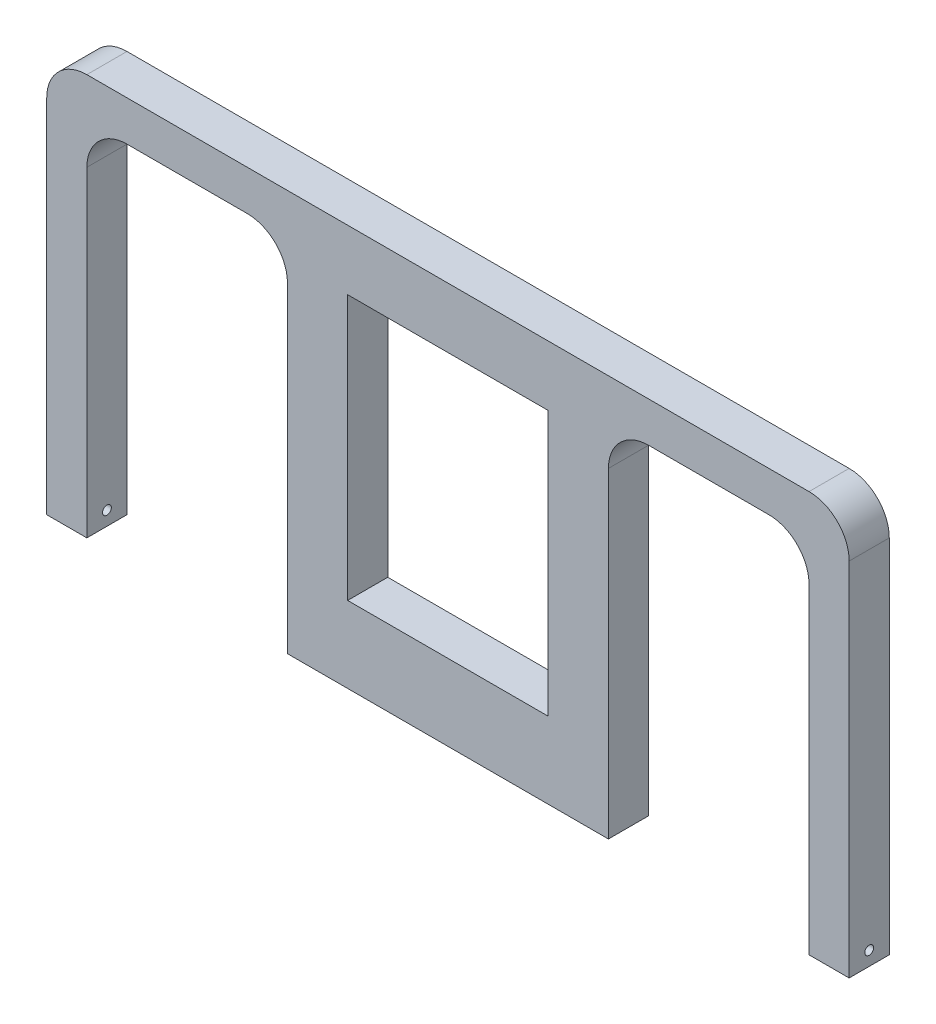
from build123d import *

# Parameters (mm, degrees)
SKETCH1_W             = 12.7
SKETCH1_H             = 12.7
BOSS_EXTRUDE1_DEPTH   = 114.3
BOSS_EXTRUDE1_2_DEPTH = 114.3
SKETCH2_W             = 12.7
SKETCH2_H             = 12.7
BOSS_EXTRUDE2_DEPTH   = 254
SKETCH3_W             = 101.6
SKETCH3_H             = 12.7
BOSS_EXTRUDE3_DEPTH   = 114.3
SKETCH4_R             = 1.397
CUT_EXTRUDE1_DEPTH    = 12.7
BOSS_EXTRUDE4_DEPTH   = 12.7
CUT_EXTRUDE2_DEPTH    = 12.7
SKETCH7_W             = 63.5
SKETCH7_H             = 83.82
CUT_EXTRUDE3_DEPTH    = 12.7


with BuildPart() as part:
    # Sketch1 → Boss-Extrude1 (new body)
    with BuildSketch(Plane(origin=(0, 0, 0), x_dir=(1, 0, 0), z_dir=(0, 1, 0))):
        with Locations((-120.65, -6.35)):
            Rectangle(SKETCH1_W, SKETCH1_H)
    extrude(amount=BOSS_EXTRUDE1_DEPTH)



with BuildPart() as body_2:
    # Sketch1 → Boss-Extrude1 2 (new body)
    with BuildSketch(Plane(origin=(0, 0, 0), x_dir=(1, 0, 0), z_dir=(0, 1, 0))):
        with Locations((120.65, -6.35)):
            Rectangle(SKETCH1_W, SKETCH1_H)
    extrude(amount=BOSS_EXTRUDE1_2_DEPTH)


with BuildPart() as part_1:
    add(part.part)

    add(body_2.part)  # Boss-Extrude2 merges body 2
    # Sketch2 → Boss-Extrude2 (add)
    with BuildSketch(Plane.ZY.offset(127)):
        with Locations((6.35, 120.65)):
            Rectangle(SKETCH2_W, SKETCH2_H)
    extrude(amount=-BOSS_EXTRUDE2_DEPTH)

    # Sketch3 → Boss-Extrude3 (add)
    with BuildSketch(Plane.XZ.offset(-114.3)):
        with Locations((0, 6.35)):
            Rectangle(SKETCH3_W, SKETCH3_H)
    extrude(amount=BOSS_EXTRUDE3_DEPTH)

    # Sketch4 → Cut-Extrude1 (cut)
    with BuildSketch(Plane(origin=(127, 0, 0), x_dir=(0, 0, -1), z_dir=(1, 0, 0))):
        with Locations((-6.35, 4.445)):
            Circle(SKETCH4_R)
    cut_extrude1 = extrude(amount=-CUT_EXTRUDE1_DEPTH, mode=Mode.SUBTRACT)

    # Mirror1: Cut-Extrude1 across plane
    add(cut_extrude1.mirror(Plane(origin=(0, 0, 0), x_dir=(0, 0, 1), z_dir=(1, 0, 0))), mode=Mode.SUBTRACT)

    # Sketch5 → Boss-Extrude4 (add)
    with BuildSketch(Plane(origin=(0, 0, 0), x_dir=(-1, 0, 0), z_dir=(0, 0, -1))):
        with BuildLine():
            Line((-114.3, 114.3), (-114.3, 101.6))
            ThreePointArc((-114.3, 101.6), (-110.580256121, 110.580256121), (-101.6, 114.3))
            Line((-101.6, 114.3), (-114.3, 114.3))
        make_face()
        with BuildLine():
            Line((-50.8, 114.3), (-63.5, 114.3))
            ThreePointArc((-63.5, 114.3), (-54.519743879, 110.580256121), (-50.8, 101.6))
            Line((-50.8, 101.6), (-50.8, 114.3))
        make_face()
    boss_extrude4 = extrude(amount=-BOSS_EXTRUDE4_DEPTH)

    # Mirror2: Boss-Extrude4 across plane
    add(boss_extrude4.mirror(Plane(origin=(0, 0, 0), x_dir=(0, 0, 1), z_dir=(1, 0, 0))))

    # Sketch6 → Cut-Extrude2 (cut)
    with BuildSketch(Plane(origin=(0, 0, 0), x_dir=(-1, 0, 0), z_dir=(0, 0, -1))):
        with BuildLine():
            Line((-127, 127), (-127, 114.3))
            ThreePointArc((-127, 114.3), (-123.280256121, 123.280256121), (-114.3, 127))
            Line((-114.3, 127), (-127, 127))
        make_face()
    cut_extrude2 = extrude(amount=-CUT_EXTRUDE2_DEPTH, mode=Mode.SUBTRACT)

    # Mirror3: Cut-Extrude2 across plane
    add(cut_extrude2.mirror(Plane(origin=(0, 0, 0), x_dir=(0, 0, 1), z_dir=(1, 0, 0))), mode=Mode.SUBTRACT)

    # Sketch7 → Cut-Extrude3 (cut)
    with BuildSketch(Plane(origin=(0, 0, 0), x_dir=(-1, 0, 0), z_dir=(0, 0, -1))):
        with Locations((0, 66.04)):
            Rectangle(SKETCH7_W, SKETCH7_H)
    extrude(amount=-CUT_EXTRUDE3_DEPTH, mode=Mode.SUBTRACT)


solid = part_1.part
